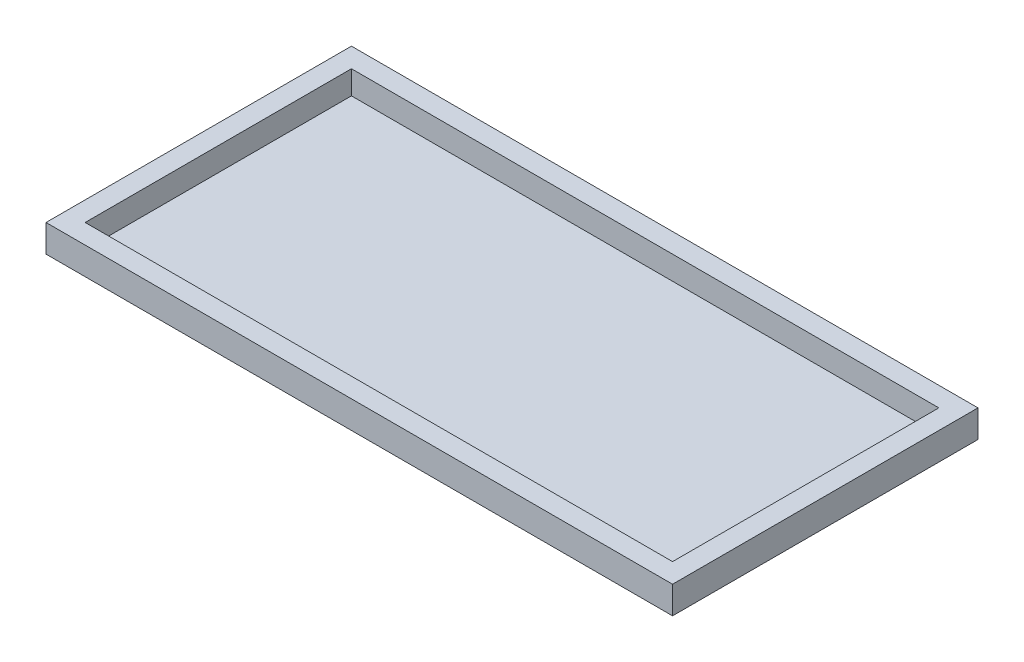
from build123d import *

# Parameters (mm, degrees)
CROQUIS1_W              = 160
CROQUIS1_H              = 78
CROQUIS1_W_2            = 150
CROQUIS1_H_2            = 68
SALIENTE_EXTRUIR1_DEPTH = 6
CROQUIS2_W              = 160
CROQUIS2_H              = 78
SALIENTE_EXTRUIR2_DEPTH = 1


with BuildPart() as part:
    # Croquis1 → Saliente-Extruir1 (new body)
    with BuildSketch(Plane(origin=(0, 0, 0), x_dir=(1, 0, 0), z_dir=(0, 1, 0))):
        Rectangle(CROQUIS1_W, CROQUIS1_H)
        Rectangle(CROQUIS1_W_2, CROQUIS1_H_2, mode=Mode.SUBTRACT)
    extrude(amount=SALIENTE_EXTRUIR1_DEPTH)

    # Croquis2 → Saliente-Extruir2 (add)
    with BuildSketch(Plane.XZ):
        Rectangle(CROQUIS2_W, CROQUIS2_H)
    extrude(amount=SALIENTE_EXTRUIR2_DEPTH)


solid = part.part
